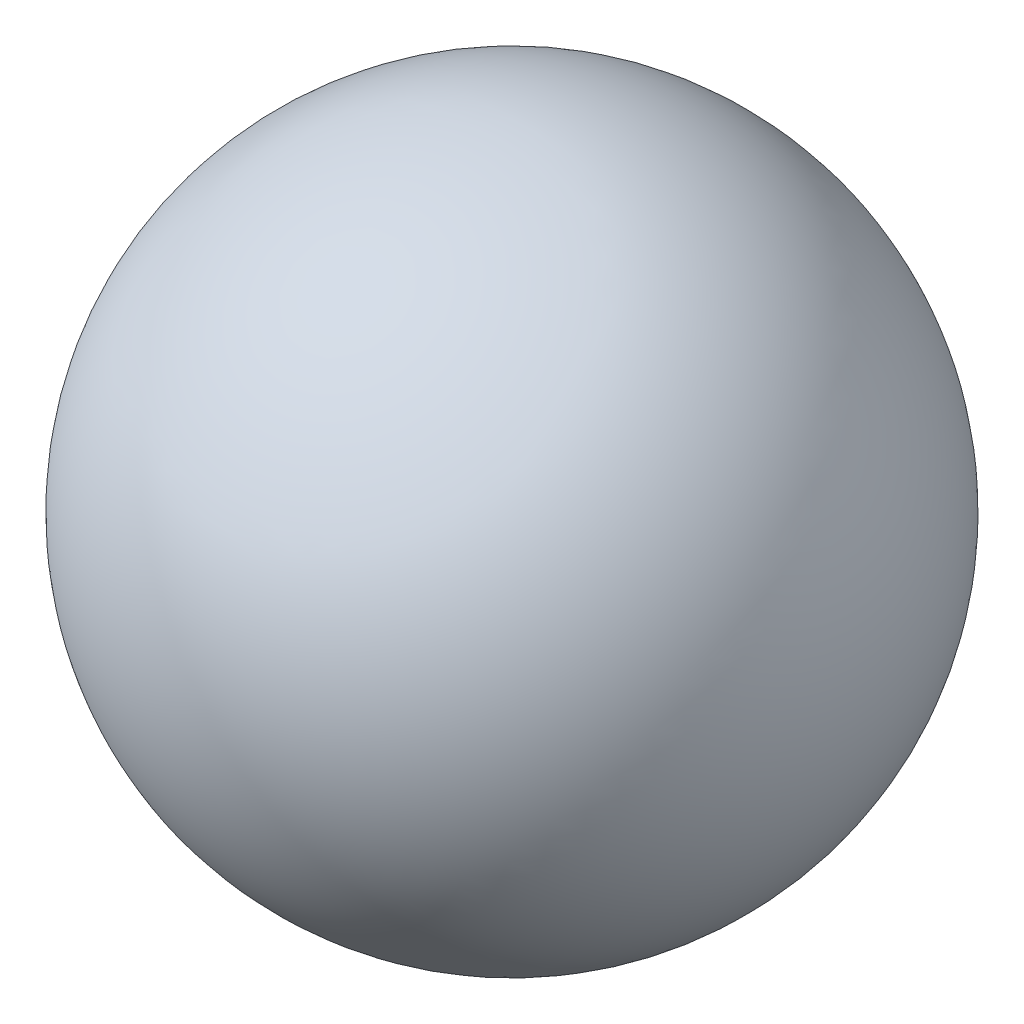
from build123d import *


with BuildPart() as part:
    # Sketch1 → Revolve1 (revolve)
    with BuildSketch(Plane(origin=(0, 0, 0), x_dir=(1, 0, 0), z_dir=(0, 1, 0))):
        with BuildLine():
            Line((0, 6.35), (0, -6.35))
            ThreePointArc((0, -6.35), (-6.35, 0), (0, 6.35))
        make_face()
    revolve(axis=Axis((0, 0, -6.35), (0, 0, 1)))


solid = part.part
